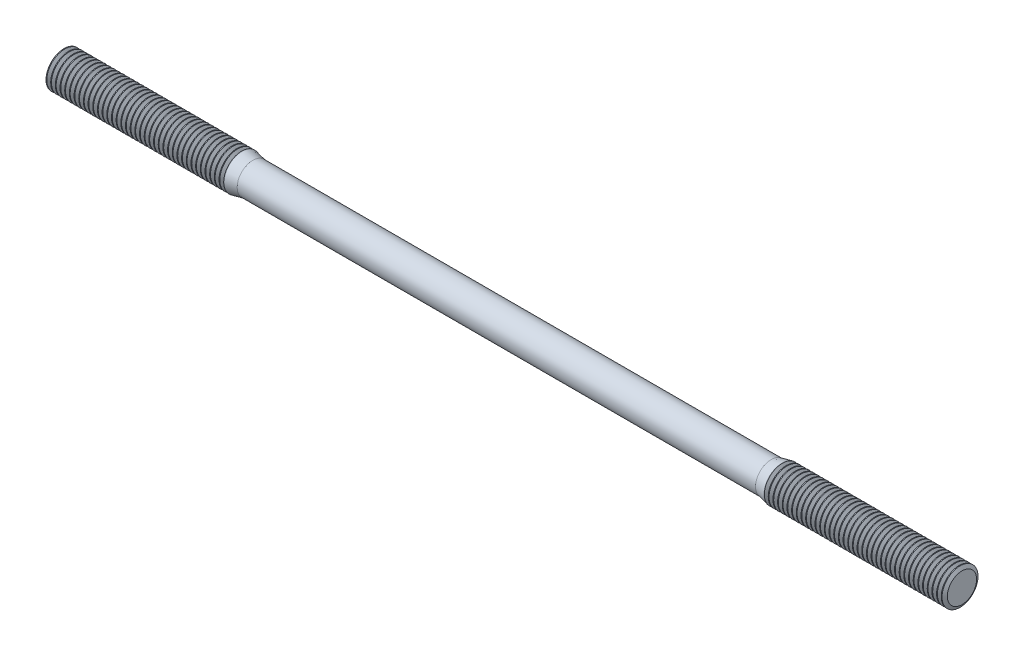
from build123d import *

# Parameters (mm, degrees)
SKETCH2_R       = 0.87
BASEBODY_DEPTH  = 50
LPATTERN1_COUNT = 39
LPATTERN1_PITCH = 0.2598
LPATTERN2_COUNT = 39
LPATTERN2_PITCH = 0.2598


with BuildPart() as part:
    # Sketch2 → BaseBody (new body)
    with BuildSketch(Plane(origin=(0, 0, 0), x_dir=(0, 0, -1), z_dir=(1, 0, 0))):
        Circle(SKETCH2_R)
    extrude(amount=BASEBODY_DEPTH)

    # Sketch3 → BaseHead (revolve)
    with BuildSketch(Plane.XY):
        Polygon((50, 1), (50, 0), (39.4, 0), (39.4, 0.87), (40, 1), align=None)
    revolve(axis=Axis((-0.442011354, 0, 0), (1, 0, 0)))

    # Sketch8 → Cut-Revolve1 (revolve, cut)
    with BuildSketch(Plane.XY):
        Polygon((50, 0.8125055), (50.10825, 1), (50.10825, 1.2165), (49.89175, 1.2165), (49.89175, 1), align=None)
    cut_revolve1 = revolve(axis=Axis((0, 0, 0), (1, 0, 0)), mode=Mode.SUBTRACT)

    # LPattern1: Cut-Revolve1 ×39
    with Locations(*[(-i * LPATTERN1_PITCH, 0, 0) for i in range(1, LPATTERN1_COUNT)]):
        add(cut_revolve1, mode=Mode.SUBTRACT)

    # Sketch6 → BaseEnd (revolve)
    with BuildSketch(Plane.XY):
        Polygon((0, 0), (0, 1), (10, 1), (10.6, 0.87), (10.6, 0), align=None)
    revolve(axis=Axis((-0.377128954, 0, 0), (1, 0, 0)))

    # Sketch9 → Cut-Revolve2 (revolve, cut)
    with BuildSketch(Plane.XY):
        Polygon((0, 0.8125055), (0.10825, 1), (0.10825, 1.2165), (-0.10825, 1.2165), (-0.10825, 1), align=None)
    cut_revolve2 = revolve(axis=Axis((0, 0, 0), (1, 0, 0)), mode=Mode.SUBTRACT)

    # LPattern2: Cut-Revolve2 ×39
    with Locations(*[(i * LPATTERN2_PITCH, 0, 0) for i in range(1, LPATTERN2_COUNT)]):
        add(cut_revolve2, mode=Mode.SUBTRACT)


solid = part.part
